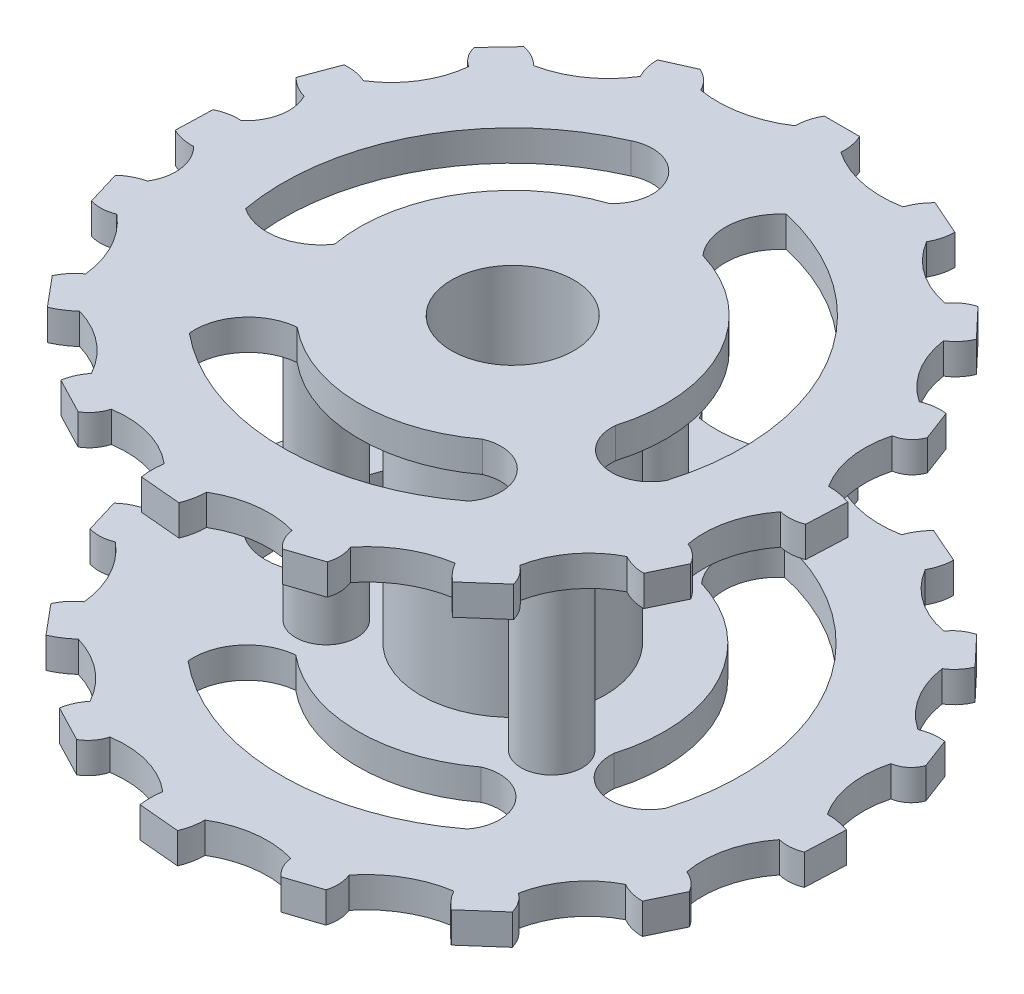
from build123d import *

# Parameters (mm, degrees)
CROQUIS1_R               = 1
CROQUIS1_R_2             = 1.5
SALIENTE_EXTRUIR1_DEPTH  = 2
CROQUIS2_R               = 2
SALIENTE_EXTRUIR2_DEPTH  = 16.5
SALIENTE_EXTRUIR21_DEPTH = 2
CROQUIS5_6_R             = 10
CROQUIS5_6_R_2           = 4
SALIENTE_EXTRUIR28_DEPTH = 2
CROQUIS7_R               = 6
CROQUIS7_R_2             = 4
SALIENTE_EXTRUIR29_DEPTH = 16.5


with BuildPart() as part:
    # Croquis1 → Saliente-Extruir1 (new body)
    with BuildSketch(Plane(origin=(0, 0, 0), x_dir=(1, 0, 0), z_dir=(0, 1, 0))):
        with BuildLine():
            Line((9.737003893, 19.141251086), (7.417986398, 20.166615233))
            ThreePointArc((7.417986398, 20.166615233), (6.937358939, 19.5689166), (6.603694272, 18.878326779))
            ThreePointArc((6.603694272, 18.878326779), (3.939228807, 18.898951454), (1.488032498, 19.943670675))
            ThreePointArc((1.488032498, 19.943670675), (1.445958552, 20.713765252), (1.208709961, 21.44761059))
            Line((1.208709961, 21.44761059), (-1.093924694, 21.44761059))
            ThreePointArc((-1.093924694, 21.44761059), (-1.39669541, 20.722569324), (-1.5, 19.943670675))
            ThreePointArc((-1.5, 19.943670675), (-3.95058631, 18.925893129), (-6.603694269, 18.87832678))
            ThreePointArc((-6.603694269, 18.87832678), (-7.097871549, 19.565119628), (-7.801843538, 20.034501177))
            Line((-7.801843538, 20.034501177), (-9.722782755, 19.175961397))
            ThreePointArc((-9.722782755, 19.175961397), (-9.628525857, 18.404861989), (-9.351305731, 17.679170827))
            ThreePointArc((-9.351305731, 17.679170827), (-11.097309405, 15.817597399), (-13.441932653, 14.809268941))
            ThreePointArc((-13.441932653, 14.809268941), (-14.081603263, 15.284877845), (-14.825671171, 15.570789136))
            Line((-14.825671171, 15.570789136), (-16.404268945, 13.897840134))
            ThreePointArc((-16.404268945, 13.897840134), (-16.081520147, 13.175203348), (-15.505607342, 12.63234503))
            ThreePointArc((-15.505607342, 12.63234503), (-16.334969826, 10.205203073), (-18.152580264, 8.395464832))
            ThreePointArc((-18.152580264, 8.395464832), (-18.897654977, 8.628646461), (-19.677626574, 8.662621568))
            Line((-19.677626574, 8.662621568), (-20.529973014, 6.385155287))
            ThreePointArc((-20.529973014, 6.385155287), (-19.920551511, 5.896249949), (-19.205241697, 5.581997077))
            ThreePointArc((-19.205241697, 5.581997077), (-18.947406136, 3.747532871), (-19.884172578, 2.149344293))
            ThreePointArc((-19.884172578, 2.149344293), (-20.672468319, 2.100263473), (-21.420531338, 1.846845199))
            Line((-21.420531338, 1.846845199), (-21.493196274, -0.540845579))
            ThreePointArc((-21.493196274, -0.540845579), (-20.758053488, -0.802297757), (-19.980366438, -0.865503837))
            ThreePointArc((-19.980366438, -0.865503837), (-19.143058661, -2.519738655), (-19.524743503, -4.334096345))
            ThreePointArc((-19.524743503, -4.334096345), (-20.258754051, -4.601438452), (-20.898605541, -5.049582799))
            Line((-20.898605541, -5.049582799), (-20.227722472, -7.286236586))
            ThreePointArc((-20.227722472, -7.286236586), (-19.435426494, -7.381627116), (-18.657322406, -7.204465326))
            ThreePointArc((-18.657322406, -7.204465326), (-17.042946572, -9.172382115), (-16.289669226, -11.603735455))
            ThreePointArc((-16.289669226, -11.603735455), (-16.861750462, -12.134066692), (-17.280128779, -12.792464555))
            Line((-17.280128779, -12.792464555), (-15.65238006, -14.739504688))
            ThreePointArc((-15.65238006, -14.739504688), (-14.979307591, -14.374547881), (-14.371321567, -13.909173823))
            ThreePointArc((-14.371321567, -13.909173823), (-12.110540974, -15.084231793), (-10.474670026, -17.03764326))
            ThreePointArc((-10.474670026, -17.03764326), (-10.872869774, -17.687089425), (-11.095889446, -18.415516213))
            Line((-11.095889446, -18.415516213), (-8.743233651, -19.641941486))
            ThreePointArc((-8.743233651, -19.641941486), (-8.154841135, -19.119072083), (-7.801843538, -18.415516213))
            ThreePointArc((-7.801843538, -18.415516213), (-5.2463547, -18.565601776), (-2.990266287, -19.775194248))
            ThreePointArc((-2.990266287, -19.775194248), (-3.046016891, -20.516764032), (-2.990266287, -21.258333816))
            Line((-2.990266287, -21.258333816), (-0.302267325, -21.497875115))
            ThreePointArc((-0.302267325, -21.497875115), (-0.076320867, -20.764034586), (0, -20))
            ThreePointArc((0, -20), (2.417094435, -19.170088794), (4.964544807, -19.374036618))
            ThreePointArc((4.964544807, -19.374036618), (5.20286964, -20.120879855), (5.69326733, -20.732503638))
            Line((5.69326733, -20.732503638), (7.889866919, -20))
            ThreePointArc((7.889866919, -20), (7.992890087, -19.19858267), (7.812672693, -18.410924621))
            ThreePointArc((7.812672693, -18.410924621), (9.736848667, -16.747529924), (12.134385598, -15.898323376))
            ThreePointArc((12.134385598, -15.898323376), (12.571653893, -16.513007216), (13.113684156, -17.03764326))
            Line((13.113684156, -17.03764326), (15.234810959, -15.170713069))
            ThreePointArc((15.234810959, -15.170713069), (14.907076756, -14.468751085), (14.371321567, -13.909173823))
            ThreePointArc((14.371321567, -13.909173823), (15.408707684, -11.561788617), (17.372451112, -9.909487492))
            ThreePointArc((17.372451112, -9.909487492), (18.094766396, -10.205373901), (18.868789877, -10.306249006))
            Line((18.868789877, -10.306249006), (19.86079474, -8.234004634))
            ThreePointArc((19.86079474, -8.234004634), (19.347198737, -7.616204189), (18.657322406, -7.204465326))
            ThreePointArc((18.657322406, -7.204465326), (18.731672162, -4.649135188), (19.86079474, -2.355595957))
            ThreePointArc((19.86079474, -2.355595957), (20.63004566, -2.42207864), (21.382194569, -2.247611041))
            Line((21.382194569, -2.247611041), (21.496537424, 0.385848129))
            ThreePointArc((21.496537424, 0.385848129), (20.754342421, 0.58206395), (19.98949571, 0.648121342))
            ThreePointArc((19.98949571, 0.648121342), (19.070562892, 3.031321881), (19.205241697, 5.581997077))
            ThreePointArc((19.205241697, 5.581997077), (19.972733234, 5.929730571), (20.455311513, 6.620440385))
            Line((20.455311513, 6.620440385), (19.701763238, 8.607585335))
            ThreePointArc((19.701763238, 8.607585335), (18.913330915, 8.602609078), (18.152580264, 8.395464832))
            ThreePointArc((18.152580264, 8.395464832), (16.380572032, 10.233692858), (15.505607342, 12.63234503))
            ThreePointArc((15.505607342, 12.63234503), (16.088686801, 13.137620816), (16.489022308, 13.797178818))
            Line((16.489022308, 13.797178818), (14.69374178, 15.695348114))
            ThreePointArc((14.69374178, 15.695348114), (13.991092282, 15.36073), (13.441932653, 14.809268941))
            ThreePointArc((13.441932653, 14.809268941), (11.084000862, 15.798628013), (9.351305729, 17.679170828))
            ThreePointArc((9.351305729, 17.679170828), (9.638957734, 18.385201856), (9.737003893, 19.141251086))
        make_face()
        with Locations((-7.363406012, -4.726812024)):
            Circle(CROQUIS1_R, mode=Mode.SUBTRACT)
        with BuildLine():
            ThreePointArc((-6.005552962, 13.745302238), (-2.728183392, 12.853840042), (-3.165703477, 9.485690354))
            ThreePointArc((-3.165703477, 9.485690354), (-8.605491026, 5.093674921), (-9.838820922, -1.788184239))
            ThreePointArc((-9.838820922, -1.788184239), (-12.113353611, -3.254073564), (-14.758231382, -2.682276358))
            ThreePointArc((-14.758231382, -2.682276358), (-13.238203039, 7.053366592), (-6.005552962, 13.745302238))
        make_face(mode=Mode.SUBTRACT)
        with BuildLine():
            ThreePointArc((9.061854108, -11.953359366), (-0.316147018, -14.996667999), (-9.557560502, -11.560840681))
            ThreePointArc((-9.557560502, -11.560840681), (-8.762743252, -8.974222037), (-6.371707002, -7.707227121))
            ThreePointArc((-6.371707002, -7.707227121), (-0.226423237, -9.997436297), (6.01624419, -7.98779105))
            ThreePointArc((6.01624419, -7.98779105), (9.068504807, -8.795932646), (9.061854108, -11.953359366))
        make_face(mode=Mode.SUBTRACT)
        with Locations((7.363406012, -4.726812024)):
            Circle(CROQUIS1_R, mode=Mode.SUBTRACT)
        Circle(CROQUIS1_R_2, mode=Mode.SUBTRACT)
        with BuildLine():
            ThreePointArc((3.201145458, 14.654441912), (12.922390936, 7.616548596), (14.371321567, -4.297105587))
            ThreePointArc((14.371321567, -4.297105587), (11.387715863, -5.548728775), (9.580881044, -2.864737058))
            ThreePointArc((9.580881044, -2.864737058), (8.790915707, 4.766529244), (2.826593594, 9.592203535))
            ThreePointArc((2.826593594, 9.592203535), (1.965445631, 12.200894954), (3.201145458, 14.654441912))
        make_face(mode=Mode.SUBTRACT)
        with Locations((0, 8.75)):
            Circle(CROQUIS1_R, mode=Mode.SUBTRACT)
    extrude(amount=SALIENTE_EXTRUIR1_DEPTH)

    # Croquis2 → Saliente-Extruir2 (add)
    with BuildSketch(Plane(origin=(0, 2, 0), x_dir=(1, 0, 0), z_dir=(0, 1, 0))):
        with Locations((-7.363406012, -4.726812024)):
            Circle(CROQUIS2_R)
        with Locations((7.363406012, -4.726812024)):
            Circle(CROQUIS2_R)
        with Locations((0, 8.75)):
            Circle(CROQUIS2_R)
    extrude(amount=SALIENTE_EXTRUIR2_DEPTH)

    # Croquis5 → Saliente-Extruir21 (add)
    with BuildSketch(Plane(origin=(0, 18.5, 0), x_dir=(1, 0, 0), z_dir=(0, 1, 0))):
        with BuildLine():
            Line((9.737003893, 19.230045123), (7.417986398, 20.25540927))
            ThreePointArc((7.417986398, 20.25540927), (6.937358939, 19.657710637), (6.603694272, 18.967120816))
            ThreePointArc((6.603694272, 18.967120816), (3.939228807, 18.987745491), (1.488032498, 20.032464712))
            ThreePointArc((1.488032498, 20.032464712), (1.445958552, 20.802559289), (1.208709961, 21.536404626))
            Line((1.208709961, 21.536404626), (-1.093924694, 21.536404626))
            ThreePointArc((-1.093924694, 21.536404626), (-1.39669541, 20.811363361), (-1.5, 20.032464712))
            ThreePointArc((-1.5, 20.032464712), (-3.95058631, 19.014687166), (-6.603694269, 18.967120817))
            ThreePointArc((-6.603694269, 18.967120817), (-7.097871549, 19.653913665), (-7.801843538, 20.123295214))
            Line((-7.801843538, 20.123295214), (-9.722782755, 19.264755434))
            ThreePointArc((-9.722782755, 19.264755434), (-9.628525857, 18.493656025), (-9.351305731, 17.767964864))
            ThreePointArc((-9.351305731, 17.767964864), (-11.097309405, 15.906391436), (-13.441932653, 14.898062978))
            ThreePointArc((-13.441932653, 14.898062978), (-14.081603263, 15.373671882), (-14.825671171, 15.659583173))
            Line((-14.825671171, 15.659583173), (-16.404268945, 13.986634171))
            ThreePointArc((-16.404268945, 13.986634171), (-16.081520147, 13.263997385), (-15.505607342, 12.721139067))
            ThreePointArc((-15.505607342, 12.721139067), (-16.334969826, 10.29399711), (-18.152580264, 8.484258869))
            ThreePointArc((-18.152580264, 8.484258869), (-18.897654977, 8.717440498), (-19.677626574, 8.751415605))
            Line((-19.677626574, 8.751415605), (-20.529973014, 6.473949324))
            ThreePointArc((-20.529973014, 6.473949324), (-19.920551511, 5.985043986), (-19.205241697, 5.670791114))
            ThreePointArc((-19.205241697, 5.670791114), (-18.947406136, 3.836326908), (-19.884172578, 2.23813833))
            ThreePointArc((-19.884172578, 2.23813833), (-20.672468319, 2.18905751), (-21.420531338, 1.935639236))
            Line((-21.420531338, 1.935639236), (-21.493196274, -0.452051542))
            ThreePointArc((-21.493196274, -0.452051542), (-20.758053488, -0.71350372), (-19.980366438, -0.7767098))
            ThreePointArc((-19.980366438, -0.7767098), (-19.143058661, -2.430944618), (-19.524743503, -4.245302308))
            ThreePointArc((-19.524743503, -4.245302308), (-20.258754051, -4.512644415), (-20.898605541, -4.960788762))
            Line((-20.898605541, -4.960788762), (-20.227722472, -7.197442549))
            ThreePointArc((-20.227722472, -7.197442549), (-19.435426494, -7.292833079), (-18.657322406, -7.115671289))
            ThreePointArc((-18.657322406, -7.115671289), (-17.042946572, -9.083588079), (-16.289669226, -11.514941418))
            ThreePointArc((-16.289669226, -11.514941418), (-16.861750462, -12.045272655), (-17.280128779, -12.703670518))
            Line((-17.280128779, -12.703670518), (-15.65238006, -14.650710651))
            ThreePointArc((-15.65238006, -14.650710651), (-14.979307591, -14.285753844), (-14.371321567, -13.820379786))
            ThreePointArc((-14.371321567, -13.820379786), (-12.110540974, -14.995437756), (-10.474670026, -16.948849223))
            ThreePointArc((-10.474670026, -16.948849223), (-10.872869774, -17.598295388), (-11.095889446, -18.326722177))
            Line((-11.095889446, -18.326722177), (-8.743233651, -19.553147449))
            ThreePointArc((-8.743233651, -19.553147449), (-8.154841135, -19.030278046), (-7.801843538, -18.326722177))
            ThreePointArc((-7.801843538, -18.326722177), (-5.2463547, -18.476807739), (-2.990266287, -19.686400211))
            ThreePointArc((-2.990266287, -19.686400211), (-3.046016891, -20.427969995), (-2.990266287, -21.169539779))
            Line((-2.990266287, -21.169539779), (-0.302267325, -21.409081078))
            ThreePointArc((-0.302267325, -21.409081078), (-0.076320867, -20.675240549), (0, -19.911205963))
            ThreePointArc((0, -19.911205963), (2.417094435, -19.081294757), (4.964544807, -19.285242581))
            ThreePointArc((4.964544807, -19.285242581), (5.20286964, -20.032085818), (5.69326733, -20.643709601))
            Line((5.69326733, -20.643709601), (7.889866919, -19.911205963))
            ThreePointArc((7.889866919, -19.911205963), (7.992890087, -19.109788633), (7.812672693, -18.322130584))
            ThreePointArc((7.812672693, -18.322130584), (9.736848667, -16.658735887), (12.134385598, -15.809529339))
            ThreePointArc((12.134385598, -15.809529339), (12.571653893, -16.424213179), (13.113684156, -16.948849223))
            Line((13.113684156, -16.948849223), (15.234810959, -15.081919032))
            ThreePointArc((15.234810959, -15.081919032), (14.907076756, -14.379957048), (14.371321567, -13.820379786))
            ThreePointArc((14.371321567, -13.820379786), (15.408707684, -11.47299458), (17.372451112, -9.820693455))
            ThreePointArc((17.372451112, -9.820693455), (18.094766396, -10.116579864), (18.868789877, -10.217454969))
            Line((18.868789877, -10.217454969), (19.86079474, -8.145210597))
            ThreePointArc((19.86079474, -8.145210597), (19.347198737, -7.527410152), (18.657322406, -7.115671289))
            ThreePointArc((18.657322406, -7.115671289), (18.731672162, -4.560341151), (19.86079474, -2.26680192))
            ThreePointArc((19.86079474, -2.26680192), (20.63004566, -2.333284603), (21.382194569, -2.158817004))
            Line((21.382194569, -2.158817004), (21.496537424, 0.474642166))
            ThreePointArc((21.496537424, 0.474642166), (20.754342421, 0.670857987), (19.98949571, 0.736915379))
            ThreePointArc((19.98949571, 0.736915379), (19.070562892, 3.120115918), (19.205241697, 5.670791114))
            ThreePointArc((19.205241697, 5.670791114), (19.972733234, 6.018524608), (20.455311513, 6.709234422))
            Line((20.455311513, 6.709234422), (19.701763238, 8.696379372))
            ThreePointArc((19.701763238, 8.696379372), (18.913330915, 8.691403115), (18.152580264, 8.484258869))
            ThreePointArc((18.152580264, 8.484258869), (16.380572032, 10.322486895), (15.505607342, 12.721139067))
            ThreePointArc((15.505607342, 12.721139067), (16.088686801, 13.226414853), (16.489022308, 13.885972855))
            Line((16.489022308, 13.885972855), (14.69374178, 15.784142151))
            ThreePointArc((14.69374178, 15.784142151), (13.991092282, 15.449524037), (13.441932653, 14.898062978))
            ThreePointArc((13.441932653, 14.898062978), (11.084000862, 15.88742205), (9.351305729, 17.767964865))
            ThreePointArc((9.351305729, 17.767964865), (9.638957734, 18.473995893), (9.737003893, 19.230045123))
        make_face()
        with BuildLine():
            ThreePointArc((-6.005552962, 13.834096275), (-2.728183392, 12.942634079), (-3.165703477, 9.574484391))
            ThreePointArc((-3.165703477, 9.574484391), (-0.177722094, 10.087214655), (2.826593594, 9.680997572))
            ThreePointArc((2.826593594, 9.680997572), (1.965445631, 12.289688991), (3.201145458, 14.743235949))
            ThreePointArc((3.201145458, 14.743235949), (12.922390936, 7.705342633), (14.371321567, -4.20831155))
            ThreePointArc((14.371321567, -4.20831155), (11.387715863, -5.459934738), (9.580881044, -2.775943021))
            ThreePointArc((9.580881044, -2.775943021), (8.2084712, -5.62268568), (6.01624419, -7.898997013))
            ThreePointArc((6.01624419, -7.898997013), (9.068504807, -8.707138609), (9.061854108, -11.864565329))
            ThreePointArc((9.061854108, -11.864565329), (-0.316147018, -14.907873962), (-9.557560502, -11.472046644))
            ThreePointArc((-9.557560502, -11.472046644), (-8.762743252, -8.885428), (-6.371707002, -7.618433084))
            ThreePointArc((-6.371707002, -7.618433084), (-8.628677248, -4.96550403), (-9.838820922, -1.699390202))
            ThreePointArc((-9.838820922, -1.699390202), (-12.113353611, -3.165279527), (-14.758231382, -2.593482321))
            ThreePointArc((-14.758231382, -2.593482321), (-13.238203039, 7.142160629), (-6.005552962, 13.834096275))
        make_face(mode=Mode.SUBTRACT)
    extrude(amount=SALIENTE_EXTRUIR21_DEPTH)

    # Croquis5_6 → Saliente-Extruir28 (add)
    with BuildSketch(Plane(origin=(0, 18.5, 0), x_dir=(1, 0, 0), z_dir=(0, 1, 0))):
        with Locations((0, 0.088794037)):
            Circle(CROQUIS5_6_R)
        with Locations((0, 0.088794037)):
            Circle(CROQUIS5_6_R_2, mode=Mode.SUBTRACT)
    extrude(amount=SALIENTE_EXTRUIR28_DEPTH)

    # Croquis7 → Saliente-Extruir29 (add)
    with BuildSketch(Plane.XZ.offset(-18.5)):
        with Locations((0, -0.088794037)):
            Circle(CROQUIS7_R)
        with Locations((0, -0.088794037)):
            Circle(CROQUIS7_R_2, mode=Mode.SUBTRACT)
    extrude(amount=SALIENTE_EXTRUIR29_DEPTH)


solid = part.part
